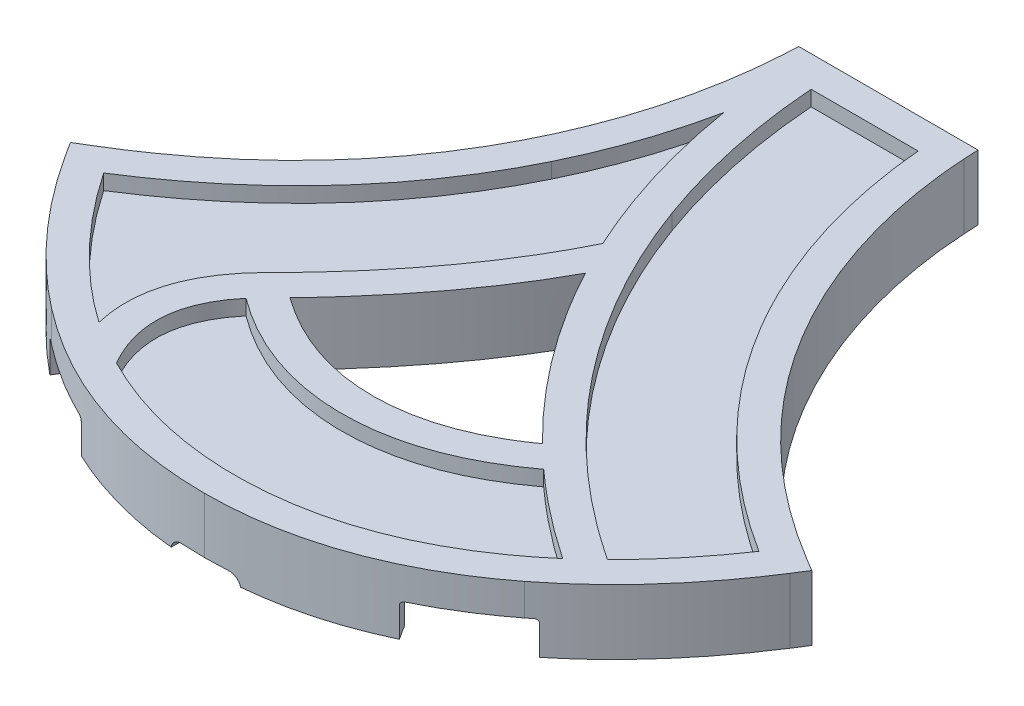
from build123d import *

# Parameters (mm, degrees)
BOSS_EXTRUDE1_DEPTH = 2.5
BOSS_EXTRUDE4_DEPTH = 4
BOSS_EXTRUDE6_DEPTH = 4
SKETCH23_R          = 1.675
CUT_EXTRUDE5_DEPTH  = 4.5
BOSS_EXTRUDE5_DEPTH = 2
BOSS_EXTRUDE7_DEPTH = 4
CUT_EXTRUDE1_DEPTH  = 15
CUT_EXTRUDE2_DEPTH  = 4
CUT_EXTRUDE3_DEPTH  = 15
CUT_EXTRUDE4_DEPTH  = 4
CUT_EXTRUDE6_DEPTH  = 0.3


with BuildPart() as part:
    # Sketch1 → Boss-Extrude1 (new body)
    with BuildSketch(Plane(origin=(0, 0, 0), x_dir=(1, 0, 0), z_dir=(0, 1, 0))):
        with BuildLine():
            Line((48.547041226, -13.77356451), (46.77347558, -12.705116653))
            add(Edge.make_bspline(
                [(46.77347558, -12.705116653), (17.003528636, 5.22980651), (12.429063845, 32.150778096), (11.844136588, 42.892659136)],
                knots=[0, 0, 0, 0, 1, 1, 1, 1], degree=3))
            Line((11.844136588, 42.892659136), (11.740234172, 44.800601737))
            Line((11.740234172, 44.800601737), (-11.731466174, 44.800601737))
            Line((-11.731466174, 44.800601737), (-11.83536859, 42.892659136))
            add(Edge.make_bspline(
                [(-11.83536859, 42.892659136), (-12.420033135, 32.1531425), (-16.994235215, 5.237425145), (-46.766415207, -12.700913268)],
                knots=[4, 4, 4, 4, 5, 5, 5, 5], degree=3))
            Line((-46.766415207, -12.700913268), (-48.539586785, -13.769361125))
            Line((-48.539586785, -13.769361125), (-47.425952543, -15.514291212))
            add(Edge.make_bspline(
                [(-47.425952543, -15.514291212), (-44.221791175, -20.535496986), (-38.763958811, -27.786861073), (-30.959324209, -33.817667318)],
                knots=[7, 7, 7, 7, 8, 8, 8, 8], degree=3))
            add(Edge.make_bspline(
                [(-30.959324209, -33.817667318), (-21.548865284, -41.089260193), (-11.131170292, -44.776416738), (0.004383999, -44.776416738)],
                knots=[8, 8, 8, 8, 9, 9, 9, 9], degree=3))
            add(Edge.make_bspline(
                [(0.004383999, -44.776416738), (11.137573886, -44.776416738), (21.55395532, -41.090311039), (30.963888823, -33.820557145)],
                knots=[9, 9, 9, 9, 10, 10, 10, 10], degree=3))
            add(Edge.make_bspline(
                [(30.963888823, -33.820557145), (38.769705626, -27.790276323), (44.228326125, -20.539437659), (47.433012916, -15.518757308)],
                knots=[10, 10, 10, 10, 11, 11, 11, 11], degree=3))
            Line((47.433012916, -15.518757308), (48.547041226, -13.77356451))
        make_face()
        with BuildLine():
            add(Edge.make_bspline(
                [(16.526280274, -17.02611406), (11.287253789, -20.800080352), (5.739508399, -22.717053662), (0.004383999, -22.717053662), (-5.746437416, -22.717053662), (-11.308763297, -20.789391276), (-16.560367097, -16.995032001)],
                knots=[0, 0, 0, 0, 1, 1, 1, 2, 2, 2, 2], degree=3))
            add(Edge.make_bspline(
                [(-16.560367097, -16.995032001), (-9.578627154, -9.767262695), (-4.026727637, -2.348009511), (0, 5.127529621)],
                knots=[2, 2, 2, 2, 3, 3, 3, 3], degree=3))
            add(Edge.make_bspline(
                [(0, 5.127529621), (3.742194614, -1.933779081), (9.0389848, -9.633214129), (16.526280274, -17.02611406)],
                knots=[3, 3, 3, 3, 4, 4, 4, 4], degree=3))
        make_face(mode=Mode.SUBTRACT)
    extrude(amount=BOSS_EXTRUDE1_DEPTH)

    # Sketch4 → Boss-Extrude4 (add)
    with BuildSketch(Plane.XZ):
        with BuildLine():
            Line((11.740234172, -44.800601737), (11.844136588, -42.892659136))
            add(Edge.make_bspline(
                [(46.77347558, 12.705116653), (17.003528636, -5.22980651), (12.429063845, -32.150778096), (11.844136588, -42.892659136)],
                knots=[0, 0, 0, 0, 1, 1, 1, 1], degree=3))
            Line((46.77347558, 12.705116653), (48.547041226, 13.77356451))
            Line((48.547041226, 13.77356451), (47.433012916, 15.518757308))
            add(Edge.make_bspline(
                [(30.963888822, 33.820557145), (38.769705626, 27.790276323), (44.228326125, 20.539437659), (47.433012916, 15.518757308)],
                knots=[10, 10, 10, 10, 11, 11, 11, 11], degree=3))
            add(Edge.make_bspline(
                [(0.004383999, 44.776416738), (11.137573886, 44.776416738), (21.55395532, 41.090311039), (30.963888823, 33.820557145)],
                knots=[9, 9, 9, 9, 10, 10, 10, 10], degree=3))
            add(Edge.make_bspline(
                [(-30.959324209, 33.817667318), (-21.548865284, 41.089260193), (-11.131170292, 44.776416738), (0.004383999, 44.776416738)],
                knots=[8, 8, 8, 8, 9, 9, 9, 9], degree=3))
            add(Edge.make_bspline(
                [(-47.425952543, 15.514291212), (-44.221791175, 20.535496986), (-38.763958811, 27.786861073), (-30.959324209, 33.817667318)],
                knots=[7, 7, 7, 7, 8, 8, 8, 8], degree=3))
            Line((-47.425952543, 15.514291212), (-48.539586785, 13.769361125))
            Line((-48.539586785, 13.769361125), (-46.766415207, 12.700913268))
            add(Edge.make_bspline(
                [(-11.83536859, -42.892659136), (-12.420033135, -32.1531425), (-16.994235215, -5.237425145), (-46.766415207, 12.700913268)],
                knots=[4, 4, 4, 4, 5, 5, 5, 5], degree=3))
            Line((-11.83536859, -42.892659136), (-11.731466174, -44.800601737))
            Line((-11.731466174, -44.800601737), (11.740234172, -44.800601737))
        make_face()
        with BuildLine():
            ThreePointArc((9.805103325, -40.070751264), (8.914967585, -41.838420571), (7.068404724, -42.550601737))
            Line((7.068404724, -42.550601737), (-7.059635396, -42.550601737))
            ThreePointArc((-7.059635396, -42.550601737), (-8.906188312, -41.838429583), (-9.79633136, -40.070777977))
            add(Edge.make_bspline(
                [(-9.79633136, -40.070777977), (-9.806604666, -39.966716592), (-9.885264947, -39.189368999), (-10.089133777, -37.474091774), (-10.520685288, -34.721752947), (-11.392209806, -30.437998952), (-13.039131532, -24.502854679), (-16.159080969, -16.744347379), (-20.674095646, -8.64514211), (-25.804589688, -1.864743805), (-30.84960564, 3.425181208), (-35.130098086, 7.285756623), (-39.088097424, 10.344941272), (-41.820471466, 12.223272957), (-42.846584297, 12.896477044), (-43.039031297, 13.021630577)],
                knots=[4.073001285, 4.073001285, 4.073001285, 4.073001285, 4.080745575, 4.130403431, 4.192357749, 4.254312068, 4.378220706, 4.502129344, 4.626037982, 4.74994662, 4.811900939, 4.873855258, 4.935809576, 4.964697167, 4.971310513, 4.971310513, 4.971310513, 4.971310513], degree=3))
            add(Edge.make_bspline(
                [(-43.039031297, 13.021630577), (-43.231478297, 13.14678411), (-44.006450367, 13.646377001), (-44.80581273, 14.143926159), (-45.400757791, 14.504556072)],
                knots=[4.971310513, 4.971310513, 4.971310513, 4.971310513, 4.977923858, 4.997763895, 4.997763895, 4.997763895, 4.997763895], degree=3))
            add(Edge.make_bspline(
                [(-45.400757791, 14.504556072), (-45.199334523, 14.817972831), (-44.805197618, 15.421588623), (-44.31229924, 16.152510125), (-43.971368584, 16.647306792), (-43.85393411, 16.816271088), (-43.794705215, 16.901116786)],
                knots=[7.013640908, 7.013640908, 7.013640908, 7.013640908, 7.075288337, 7.13550544, 7.150917297, 7.166329155, 7.166329155, 7.166329155, 7.166329155], degree=3))
            add(Edge.make_bspline(
                [(-43.794705215, 16.901116786), (-43.73547632, 16.985962483), (-43.371488665, 17.505125969), (-42.484759937, 18.737465955), (-41.011425283, 20.668321188), (-38.509551598, 23.700159309), (-35.600268698, 26.815686604), (-32.30259122, 29.847383546), (-30.497798956, 31.330829791), (-29.583579219, 32.037266879)],
                knots=[7.166329155, 7.166329155, 7.166329155, 7.166329155, 7.181741012, 7.260230625, 7.383525483, 7.506820342, 7.753410059, 7.876704917, 7.999999775, 7.999999775, 7.999999775, 7.999999775], degree=3))
            add(Edge.make_bspline(
                [(-29.583579219, 32.037266879), (-29.021484434, 32.471605303), (-27.875005392, 33.324670492), (-25.572281033, 34.90764148), (-22.640251162, 36.683922973), (-19.049635263, 38.484302425), (-14.164788894, 40.448254564), (-9.132084552, 41.758815894), (-3.965934864, 42.416362102), (-1.314502791, 42.526416738), (0.004383999, 42.526416738)],
                knots=[8.000000109, 8.000000109, 8.000000109, 8.000000109, 8.062500102, 8.125000095, 8.250000082, 8.375000068, 8.500000055, 8.750000027, 8.875000014, 9, 9, 9, 9], degree=3))
            add(Edge.make_bspline(
                [(0.004383999, 42.526416738), (1.322997387, 42.526416738), (3.973859488, 42.416394049), (9.139064598, 41.759033383), (14.170998845, 40.448831174), (19.055251222, 38.485399296), (22.645500719, 36.685488718), (25.577288185, 34.909662462), (27.879854434, 33.327093039), (29.026265905, 32.47424204), (29.588330417, 32.040012545)],
                knots=[9, 9, 9, 9, 9.125000061, 9.250000123, 9.500000245, 9.625000306, 9.750000368, 9.875000429, 9.93750046, 10.00000049, 10.00000049, 10.00000049, 10.00000049], degree=3))
            add(Edge.make_bspline(
                [(29.588330417, 32.040012545), (30.50268272, 31.333641732), (32.307756946, 29.850316117), (35.605921275, 26.818878382), (38.515636423, 23.703609409), (41.017883751, 20.672029865), (42.491328125, 18.741493214), (43.378103699, 17.509400822), (43.742061693, 16.99041662), (43.80130169, 16.905577471)],
                knots=[9.999999407, 9.999999407, 9.999999407, 9.999999407, 10.123293893, 10.246588378, 10.493177348, 10.616471833, 10.739766318, 10.818230456, 10.833642266, 10.833642266, 10.833642266, 10.833642266], degree=3))
            add(Edge.make_bspline(
                [(43.80130169, 16.905577471), (43.860541686, 16.820738321), (43.977998182, 16.651787163), (44.319086864, 16.156893212), (44.812166107, 15.425895465), (45.20644988, 14.822214052), (45.407907805, 14.508827514)],
                knots=[10.833642266, 10.833642266, 10.833642266, 10.833642266, 10.849054077, 10.864465888, 10.924708046, 10.986355288, 10.986355288, 10.986355288, 10.986355288], degree=3))
            add(Edge.make_bspline(
                [(45.407907805, 14.508827514), (44.812849726, 14.148169591), (44.013343118, 13.650577828), (43.23823363, 13.150932554), (43.045752709, 13.025765344)],
                knots=[0.002236341, 0.002236341, 0.002236341, 0.002236341, 0.022081342, 0.028696342, 0.028696342, 0.028696342, 0.028696342], degree=3))
            add(Edge.make_bspline(
                [(43.045752709, 13.025765344), (42.853271788, 12.900598135), (41.82742377, 12.227609173), (39.09541693, 10.349629878), (35.137863488, 7.290862821), (30.857614583, 3.430426247), (25.812878369, -1.859510107), (20.682655133, -8.640243605), (16.167852509, -16.740218222), (13.0480119, -24.499729565), (11.401107723, -30.435801971), (10.529564367, -34.720291025), (10.09795953, -37.473303909), (9.894057659, -39.189044935), (9.815377307, -39.966672637), (9.805103325, -40.070751264)],
                knots=[0.028696342, 0.028696342, 0.028696342, 0.028696342, 0.035311342, 0.064190776, 0.126145211, 0.188099646, 0.250054081, 0.373962951, 0.497871821, 0.621780691, 0.745689561, 0.807643996, 0.869598431, 0.919267543, 0.927011847, 0.927011847, 0.927011847, 0.927011847], degree=3))
        make_face(mode=Mode.SUBTRACT)
        with BuildLine():
            ThreePointArc((43.80130169, 16.905577471), (44.24586843, 14.80552987), (43.045752709, 13.025765344))
            add(Edge.make_bspline(
                [(45.407907805, 14.508827514), (44.812849726, 14.148169591), (44.013343118, 13.650577828), (43.23823363, 13.150932554), (43.045752709, 13.025765344)],
                knots=[0.002236341, 0.002236341, 0.002236341, 0.002236341, 0.022081342, 0.028696342, 0.028696342, 0.028696342, 0.028696342], degree=3))
            add(Edge.make_bspline(
                [(43.80130169, 16.905577471), (43.860541686, 16.820738321), (43.977998182, 16.651787163), (44.319086864, 16.156893212), (44.812166107, 15.425895465), (45.20644988, 14.822214052), (45.407907805, 14.508827514)],
                knots=[10.833642266, 10.833642266, 10.833642266, 10.833642266, 10.849054077, 10.864465888, 10.924708046, 10.986355288, 10.986355288, 10.986355288, 10.986355288], degree=3))
        make_face()
        with BuildLine():
            add(Edge.make_bspline(
                [(-43.039031297, 13.021630577), (-43.231478297, 13.14678411), (-44.006450367, 13.646377001), (-44.80581273, 14.143926159), (-45.400757791, 14.504556072)],
                knots=[4.971310513, 4.971310513, 4.971310513, 4.971310513, 4.977923858, 4.997763895, 4.997763895, 4.997763895, 4.997763895], degree=3))
            ThreePointArc((-43.039031297, 13.021630577), (-44.239051851, 14.801222913), (-43.794705215, 16.901116786))
            add(Edge.make_bspline(
                [(-45.400757791, 14.504556072), (-45.199334523, 14.817972831), (-44.805197618, 15.421588623), (-44.31229924, 16.152510125), (-43.971368584, 16.647306792), (-43.85393411, 16.816271088), (-43.794705215, 16.901116786)],
                knots=[7.013640908, 7.013640908, 7.013640908, 7.013640908, 7.075288337, 7.13550544, 7.150917297, 7.166329155, 7.166329155, 7.166329155, 7.166329155], degree=3))
        make_face()
        with BuildLine():
            add(Edge.make_bspline(
                [(18.561464236, 18.333050818), (18.468513073, 18.400008784), (18.204622743, 18.590075566), (17.563656149, 19.0512698), (16.574665128, 19.739291573), (14.974367301, 20.750082244), (12.932211839, 21.879677212), (9.603007896, 23.366039009), (5.327473808, 24.623488328), (0.045412031, 25.135736948), (-5.263804885, 24.635743019), (-9.549609453, 23.382446713), (-12.88923537, 21.896817249), (-14.937355843, 20.766749275), (-16.542499904, 19.754458694), (-17.548862094, 19.056086345), (-18.207846317, 18.580511083), (-18.486202434, 18.379423615), (-18.579376745, 18.312103835)],
                knots=[-0.045814481, -0.045814481, -0.045814481, -0.045814481, -0.028072413, 0.0044931, 0.075461372, 0.146429643, 0.288366187, 0.43030273, 0.714175817, 0.998048904, 1.281921991, 1.565795078, 1.707731622, 1.849668165, 1.920636437, 1.991604709, 2.026771683, 2.044513751, 2.044513751, 2.044513751, 2.044513751], degree=3))
            ThreePointArc((-18.579376745, 18.312103835), (-19.195034881, 17.228855671), (-18.779770658, 16.054114359))
            add(Edge.make_bspline(
                [(-18.779770658, 16.054114359), (-18.67958586, 15.950399151), (-18.479475319, 15.743149271), (-17.7934474, 15.031131805), (-16.162844302, 13.322118365), (-13.697949698, 10.57923691), (-10.892212401, 7.208486109), (-7.437816222, 2.692458315), (-4.798915439, -1.275880119), (-2.804827824, -4.685016446), (-2.080234341, -6.011416393), (-1.580006031, -6.938871271), (-1.393953417, -7.284205831), (-1.315217457, -7.430377562)],
                knots=[1.971300908, 1.971300908, 1.971300908, 1.971300908, 1.985650454, 2, 2.070329415, 2.226756105, 2.383182796, 2.539609486, 2.852462868, 2.930676213, 3.008889558, 3.03555208, 3.055105416, 3.055105416, 3.055105416, 3.055105416], degree=3))
            ThreePointArc((-1.315217457, -7.430377562), (0.010456844, -8.219022413), (1.330765757, -7.421427635))
            add(Edge.make_bspline(
                [(1.330765757, -7.421427635), (1.440317107, -7.214710459), (1.659442704, -6.801716289), (2.400482458, -5.413219547), (4.233261447, -2.06743675), (7.059369927, 2.349304029), (10.482267828, 6.942636294), (13.334966742, 10.396562794), (15.923476009, 13.233007565), (17.672245934, 14.992928174), (18.423225248, 15.737037399), (18.633384277, 15.94466706), (18.738631942, 16.048587822)],
                knots=[2.941450747, 2.941450747, 2.941450747, 2.941450747, 2.970725373, 3, 3.139349431, 3.45434662, 3.611845215, 3.76934381, 3.926842405, 4, 4.014056833, 4.028113667, 4.028113667, 4.028113667, 4.028113667], degree=3))
            ThreePointArc((18.738631942, 16.048587822), (19.180230847, 17.231936757), (18.561464236, 18.333050818))
        make_face()
        with BuildLine():
            add(Edge.make_bspline(
                [(0, -5.127529621), (3.742194614, 1.933779081), (9.0389848, 9.633214129), (16.526280274, 17.02611406)],
                knots=[3, 3, 3, 3, 4, 4, 4, 4], degree=3))
            add(Edge.make_bspline(
                [(-16.560367097, 16.995032001), (-9.578627154, 9.767262695), (-4.026727637, 2.348009511), (0, -5.127529621)],
                knots=[2, 2, 2, 2, 3, 3, 3, 3], degree=3))
            add(Edge.make_bspline(
                [(16.526280274, 17.02611406), (11.287253789, 20.800080352), (5.739508399, 22.717053662), (0.004383999, 22.717053662), (-5.746437416, 22.717053662), (-11.308763297, 20.789391276), (-16.560367097, 16.995032001)],
                knots=[0, 0, 0, 0, 1, 1, 1, 2, 2, 2, 2], degree=3))
        make_face(mode=Mode.SUBTRACT)
    extrude(amount=BOSS_EXTRUDE4_DEPTH)

    # Sketch15 → Boss-Extrude6 (add)
    with BuildSketch(Plane.XZ):
        with BuildLine():
            ThreePointArc((39.578382594, 17.917442115), (38.335373201, 15.831869177), (38.884461201, 13.466876745))
            ThreePointArc((38.884461201, 13.466876745), (39.348093126, 11.459484685), (38.28721892, 9.693380679))
            add(Edge.make_bspline(
                [(43.045752709, 13.025765344), (42.853271788, 12.900598135), (41.82742377, 12.227609173), (40.221396527, 11.123627344), (38.861117202, 10.125976897), (38.28721892, 9.693380679)],
                knots=[0.028696342, 0.028696342, 0.028696342, 0.028696342, 0.035311342, 0.064190776, 0.085982267, 0.085982267, 0.085982267, 0.085982267], degree=3))
            ThreePointArc((43.045752709, 13.025765344), (44.24586843, 14.80552987), (43.80130169, 16.905577471))
            add(Edge.make_bspline(
                [(40.030465817, 21.860461098), (40.357622354, 21.465654803), (41.285233935, 20.321742242), (42.491328125, 18.741493214), (43.378103699, 17.509400822), (43.742061693, 16.99041662), (43.80130169, 16.905577471)],
                knots=[10.552156845, 10.552156845, 10.552156845, 10.552156845, 10.616471833, 10.739766318, 10.818230456, 10.833642266, 10.833642266, 10.833642266, 10.833642266], degree=3))
            ThreePointArc((40.030465817, 21.860461098), (40.645090189, 19.79256582), (39.578382594, 17.917442115))
        make_face()
        with BuildLine():
            ThreePointArc((-39.571908118, 17.913503053), (-38.328607865, 15.827859379), (-38.877699691, 13.462652577))
            ThreePointArc((-38.877699691, 13.462652577), (-39.341361409, 11.455249041), (-38.280488276, 9.689123526))
            add(Edge.make_bspline(
                [(-38.280488276, 9.689123526), (-38.854148563, 10.121542429), (-40.214453624, 11.119238827), (-41.820471466, 12.223272957), (-42.846584297, 12.896477044), (-43.039031297, 13.021630577)],
                knots=[4.914028868, 4.914028868, 4.914028868, 4.914028868, 4.935809576, 4.964697167, 4.971310513, 4.971310513, 4.971310513, 4.971310513], degree=3))
            ThreePointArc((-43.039031297, 13.021630577), (-44.239051851, 14.801222913), (-43.794705215, 16.901116786))
            add(Edge.make_bspline(
                [(-43.794705215, 16.901116786), (-43.73547632, 16.985962483), (-43.371488665, 17.505125969), (-42.484759937, 18.737465955), (-41.278829762, 20.317878513), (-40.351469454, 21.461758125), (-40.024474361, 21.856467741)],
                knots=[7.166329155, 7.166329155, 7.166329155, 7.166329155, 7.181741012, 7.260230625, 7.383525483, 7.447819714, 7.447819714, 7.447819714, 7.447819714], degree=3))
            ThreePointArc((-40.024474361, 21.856467741), (-40.638845986, 19.78849659), (-39.571908118, 17.913503053))
        make_face()
        with BuildLine():
            ThreePointArc((-2.74431224, -9.677873395), (0.010339959, -13.877525526), (2.751099323, -9.668793547))
            ThreePointArc((2.751099323, -9.668793547), (2.249212243, -6.9682611), (3.003386077, -4.327051535))
            add(Edge.make_bspline(
                [(1.330765757, -7.421427635), (1.440317107, -7.214710459), (1.659442704, -6.801716289), (2.211537719, -5.767247996), (2.657752033, -4.946292282), (3.003386077, -4.327051535)],
                knots=[2.941450747, 2.941450747, 2.941450747, 2.941450747, 2.970725373, 3, 3.088890714, 3.088890714, 3.088890714, 3.088890714], degree=3))
            ThreePointArc((1.330765757, -7.421427635), (0.010456844, -8.219022413), (-1.315217457, -7.430377562))
            add(Edge.make_bspline(
                [(-3.040899779, -4.290110226), (-2.965420364, -4.421517631), (-2.566938835, -5.120482607), (-2.080234341, -6.011416393), (-1.580006031, -6.938871271), (-1.393953417, -7.284205831), (-1.315217457, -7.430377562)],
                knots=[2.912572306, 2.912572306, 2.912572306, 2.912572306, 2.930676213, 3.008889558, 3.03555208, 3.055105416, 3.055105416, 3.055105416, 3.055105416], degree=3))
            ThreePointArc((-3.040899779, -4.290110226), (-2.25277345, -6.948770076), (-2.74431224, -9.677873395))
        make_face()
    extrude(amount=BOSS_EXTRUDE6_DEPTH)

    # Sketch23 → Cut-Extrude5 (cut)
    with BuildSketch(Plane.XZ.offset(4)):
        with Locations((-41.539782977, 15.327005703)):
            Circle(SKETCH23_R)
        with Locations((0.005383187, -10.877529621)):
            Circle(SKETCH23_R)
        with Locations((41.546574957, 15.331186362)):
            Circle(SKETCH23_R)
    extrude(amount=-CUT_EXTRUDE5_DEPTH, mode=Mode.SUBTRACT)

    # Sketch12 → Boss-Extrude5 (add)
    with BuildSketch(Plane(origin=(0, 2.5, 0), x_dir=(1, 0, 0), z_dir=(0, 1, 0))):
        with BuildLine():
            Line((-46.766415207, -12.700913268), (-48.539586785, -13.769361125))
            Line((-48.539586785, -13.769361125), (-47.425952543, -15.514291212))
            add(Edge.make_bspline(
                [(-47.425952543, -15.514291212), (-44.221791175, -20.535496986), (-38.763958811, -27.786861073), (-30.959324209, -33.817667318)],
                knots=[7, 7, 7, 7, 8, 8, 8, 8], degree=3))
            add(Edge.make_bspline(
                [(-30.959324209, -33.817667318), (-21.548865284, -41.089260193), (-11.131170292, -44.776416738), (0.004383999, -44.776416738)],
                knots=[8, 8, 8, 8, 9, 9, 9, 9], degree=3))
            add(Edge.make_bspline(
                [(0.004383999, -44.776416738), (11.137573886, -44.776416738), (21.55395532, -41.090311039), (30.963888823, -33.820557145)],
                knots=[9, 9, 9, 9, 10, 10, 10, 10], degree=3))
            add(Edge.make_bspline(
                [(30.963888823, -33.820557145), (38.769705626, -27.790276323), (44.228326125, -20.539437659), (47.433012916, -15.518757308)],
                knots=[10, 10, 10, 10, 11, 11, 11, 11], degree=3))
            Line((47.433012916, -15.518757308), (48.547041226, -13.77356451))
            Line((48.547041226, -13.77356451), (46.77347558, -12.705116653))
            add(Edge.make_bspline(
                [(46.77347558, -12.705116653), (17.003528636, 5.22980651), (12.429063845, 32.150778096), (11.844136588, 42.892659136)],
                knots=[0, 0, 0, 0, 1, 1, 1, 1], degree=3))
            Line((11.844136588, 42.892659136), (11.740234172, 44.800601737))
            Line((11.740234172, 44.800601737), (-11.731466174, 44.800601737))
            Line((-11.731466174, 44.800601737), (-11.83536859, 42.892659136))
            add(Edge.make_bspline(
                [(-11.83536859, 42.892659136), (-12.420033135, 32.1531425), (-16.994235215, 5.237425145), (-46.766415207, -12.700913268)],
                knots=[4, 4, 4, 4, 5, 5, 5, 5], degree=3))
        make_face()
        with BuildLine():
            Line((-6.075253754, 40.765352394), (7.946679451, 40.765352394))
            add(Edge.make_bspline(
                [(7.946679451, 40.765352394), (8.483530495, 34.33798307), (10.170926753, 25.254994087), (14.899209154, 15.549116028)],
                knots=[3, 3, 3, 3, 4, 4, 4, 4], degree=3))
            add(Edge.make_bspline(
                [(14.899209154, 15.549116028), (20.914646773, 3.201016598), (30.331936199, -7.088081093), (42.906887049, -15.058749392)],
                knots=[4, 4, 4, 4, 5, 5, 5, 5], degree=3))
            add(Edge.make_bspline(
                [(42.906887049, -15.058749392), (40.659012127, -18.38065479), (37.675610555, -22.224732226), (33.936157993, -25.911002119)],
                knots=[5, 5, 5, 5, 6, 6, 6, 6], degree=3))
            add(Edge.make_bspline(
                [(33.936157993, -25.911002119), (13.025632507, -12.135114696), (3.309968443, 5.324399086), (-1.165733226, 17.6611855)],
                knots=[0, 0, 0, 0, 1, 1, 1, 1], degree=3))
            add(Edge.make_bspline(
                [(-1.165733226, 17.6611855), (-4.454734004, 26.727032556), (-5.669774903, 34.935701095), (-6.075253754, 40.765352394)],
                knots=[1, 1, 1, 1, 2, 2, 2, 2], degree=3))
        make_face(mode=Mode.SUBTRACT)
        with BuildLine():
            add(Edge.make_bspline(
                [(-26.267115388, -32.302790447), (-33.773473868, -27.088343912), (-39.285999492, -20.396292706), (-42.899826676, -15.054546007)],
                knots=[6, 6, 6, 6, 7, 7, 7, 7], degree=3))
            add(Edge.make_bspline(
                [(-42.899826676, -15.054546007), (-30.326189384, -7.083877708), (-20.909031314, 3.204694559), (-14.892674204, 15.55121772)],
                knots=[0, 0, 0, 0, 1, 1, 1, 1], degree=3))
            add(Edge.make_bspline(
                [(-14.892674204, 15.55121772), (-11.960583481, 21.568297287), (-10.198248754, 27.344092718), (-9.153674809, 32.396791039)],
                knots=[1, 1, 1, 1, 2, 2, 2, 2], degree=3))
            add(Edge.make_bspline(
                [(-9.153674809, 32.396791039), (-8.369595781, 27.60879102), (-7.074263666, 22.115509017), (-4.959025235, 16.285102424)],
                knots=[2, 2, 2, 2, 3, 3, 3, 3], degree=3))
            add(Edge.make_bspline(
                [(-4.959025235, 16.285102424), (-4.200724778, 14.194854429), (-3.298458394, 11.963957241), (-2.227202807, 9.632343014)],
                knots=[3, 3, 3, 3, 4, 4, 4, 4], degree=3))
            add(Edge.make_bspline(
                [(-2.227202807, 9.632343014), (-6.405876235, 1.067437618), (-12.722414125, -7.478995873), (-21.02725151, -15.783833258)],
                knots=[4, 4, 4, 4, 5, 5, 5, 5], degree=3))
            add(Edge.make_bspline(
                [(-21.02725151, -15.783833258), (-25.949956874, -20.706637139), (-27.720025172, -26.418068241), (-26.267115388, -32.302790447)],
                knots=[5, 5, 5, 5, 6, 6, 6, 6], degree=3))
        make_face(mode=Mode.SUBTRACT)
        with BuildLine():
            add(Edge.make_bspline(
                [(0, 5.127529621), (3.742194614, -1.933779081), (9.0389848, -9.633214129), (16.526280274, -17.02611406)],
                knots=[3, 3, 3, 3, 4, 4, 4, 4], degree=3))
            add(Edge.make_bspline(
                [(16.526280274, -17.02611406), (11.287253789, -20.800080352), (5.739508399, -22.717053662), (0.004383999, -22.717053662), (-5.746437416, -22.717053662), (-11.308763297, -20.789391276), (-16.560367097, -16.995032001)],
                knots=[0, 0, 0, 0, 1, 1, 1, 2, 2, 2, 2], degree=3))
            add(Edge.make_bspline(
                [(-16.560367097, -16.995032001), (-9.578627154, -9.767262695), (-4.026727637, -2.348009511), (0, 5.127529621)],
                knots=[2, 2, 2, 2, 3, 3, 3, 3], degree=3))
        make_face(mode=Mode.SUBTRACT)
        with BuildLine():
            add(Edge.make_bspline(
                [(30.883367734, -28.727680377), (23.245834094, -35.30482812), (13.001692917, -40.741167395), (0.004383999, -40.741167395), (-7.81619391, -40.741167395), (-14.63953521, -38.772571266), (-20.498446007, -35.771962087)],
                knots=[4, 4, 4, 4, 5, 5, 5, 6, 6, 6, 6], degree=3))
            add(Edge.make_bspline(
                [(-20.498446007, -35.771962087), (-23.817675032, -30.084372057), (-23.437170197, -24.768633801), (-19.371955318, -19.942655544)],
                knots=[0, 0, 0, 0, 1, 1, 1, 1], degree=3))
            add(Edge.make_bspline(
                [(-19.371955318, -19.942655544), (-13.294452096, -24.461491165), (-6.784788381, -26.752303006), (0.004383999, -26.752303006), (6.841550495, -26.752303006), (13.395563202, -24.429358259), (19.510043074, -19.846486699)],
                knots=[1, 1, 1, 1, 2, 2, 2, 3, 3, 3, 3], degree=3))
            add(Edge.make_bspline(
                [(19.510043074, -19.846486699), (22.88705222, -22.905270066), (26.661790227, -25.888967188), (30.883367734, -28.727680377)],
                knots=[3, 3, 3, 3, 4, 4, 4, 4], degree=3))
        make_face(mode=Mode.SUBTRACT)
    extrude(amount=BOSS_EXTRUDE5_DEPTH)

    # Sketch20 → Boss-Extrude7 (add)
    with BuildSketch(Plane.XZ):
        with BuildLine():
            Line((-38.280488276, 9.689123526), (-18.779770658, 16.054114359))
            ThreePointArc((-18.779770658, 16.054114359), (-19.195034881, 17.228855671), (-18.579376745, 18.312103835))
            Line((-18.579376745, 18.312103835), (-40.024474361, 21.856467741))
            ThreePointArc((-40.024474361, 21.856467741), (-40.638845986, 19.78849659), (-39.571908118, 17.913503053))
            ThreePointArc((-39.571908118, 17.913503053), (-38.328607865, 15.827859379), (-38.877699691, 13.462652577))
            ThreePointArc((-38.877699691, 13.462652577), (-39.341361409, 11.455249041), (-38.280488276, 9.689123526))
        make_face()
        with BuildLine():
            Line((38.28721892, 9.693380679), (18.738631942, 16.048587822))
            ThreePointArc((18.738631942, 16.048587822), (19.180230847, 17.231936757), (18.561464236, 18.333050818))
            Line((18.561464236, 18.333050818), (40.030465817, 21.860461098))
            ThreePointArc((40.030465817, 21.860461098), (40.645090189, 19.79256582), (39.578382594, 17.917442115))
            ThreePointArc((39.578382594, 17.917442115), (38.335373201, 15.831869177), (38.884461201, 13.466876745))
            ThreePointArc((38.884461201, 13.466876745), (39.348093126, 11.459484685), (38.28721892, 9.693380679))
        make_face()
    extrude(amount=BOSS_EXTRUDE7_DEPTH)

    # Sketch16 → Cut-Extrude1 (cut)
    with BuildSketch(Plane(origin=(-26.623119691, -4, 36.869577592), x_dir=(0.843372114, 0, 0.537329953), z_dir=(-0.537329953, 0, 0.843372114))):
        with BuildLine():
            Line((-6.141888368, -1.85), (6.158111632, -1.85))
            ThreePointArc((6.158111632, -1.85), (6.511665022, -1.703553391), (6.658111632, -1.35))
            Line((6.658111632, -1.35), (6.658111632, 3.85))
            ThreePointArc((6.658111632, 3.85), (6.511665022, 4.203553391), (6.158111632, 4.35))
            Line((6.158111632, 4.35), (-6.141888368, 4.35))
            ThreePointArc((-6.141888368, 4.35), (-6.495441759, 4.203553391), (-6.641888368, 3.85))
            Line((-6.641888368, 3.85), (-6.641888368, -1.35))
            ThreePointArc((-6.641888368, -1.35), (-6.495441759, -1.703553391), (-6.141888368, -1.85))
        make_face()
    extrude(amount=-CUT_EXTRUDE1_DEPTH, mode=Mode.SUBTRACT)

    # Sketch17 → Cut-Extrude2 (cut)
    with BuildSketch(Plane(origin=(0.004383999, -4, 44.776416738), x_dir=(1, 0, 0), z_dir=(0, 0, 1))):
        with BuildLine():
            Line((-3.077374703, -2.644999296), (3.062625297, -2.644999296))
            ThreePointArc((3.062625297, -2.644999296), (4.123285469, -2.205659468), (4.562625297, -1.144999296))
            Line((4.562625297, -1.144999296), (4.562625297, -0.294999296))
            ThreePointArc((4.562625297, -0.294999296), (4.123285469, 0.765660875), (3.062625297, 1.205000704))
            Line((3.062625297, 1.205000704), (-3.077374703, 1.205000704))
            ThreePointArc((-3.077374703, 1.205000704), (-4.138034874, 0.765660875), (-4.577374703, -0.294999296))
            Line((-4.577374703, -0.294999296), (-4.577374703, -1.144999296))
            ThreePointArc((-4.577374703, -1.144999296), (-4.138034874, -2.205659468), (-3.077374703, -2.644999296))
        make_face()
    extrude(amount=-CUT_EXTRUDE2_DEPTH, mode=Mode.SUBTRACT)

    # Sketch18 → Cut-Extrude3 (cut)
    with BuildSketch(Plane(origin=(26.631782756, -4, 36.869264143), x_dir=(0.843372249, 0, -0.53732974), z_dir=(0.53732974, 0, 0.843372249))):
        with BuildLine():
            Line((6.191428119, 4.35), (-6.108569064, 4.35))
            add(Edge.make_bspline(
                [(-6.108569064, 4.35), (-6.608568949, 4.35), (-6.608568949, 3.85)],
                knots=[0, 0, 0, 1.570796327, 1.570796327, 1.570796327], degree=2, weights=[1, 0.707106781, 1]))
            Line((-6.608568949, 3.85), (-6.608568949, -1.35))
            add(Edge.make_bspline(
                [(-6.608568949, -1.35), (-6.608568949, -1.85), (-6.108569064, -1.85)],
                knots=[4.71238898, 4.71238898, 4.71238898, 6.283185307, 6.283185307, 6.283185307], degree=2, weights=[1, 0.707106781, 1]))
            Line((-6.108569064, -1.85), (6.191428119, -1.85))
            add(Edge.make_bspline(
                [(6.191428119, -1.85), (6.691428005, -1.85), (6.691428005, -1.35)],
                knots=[0, 0, 0, 1.570796327, 1.570796327, 1.570796327], degree=2, weights=[1, 0.707106781, 1]))
            Line((6.691428005, -1.35), (6.691428005, 3.85))
            add(Edge.make_bspline(
                [(6.691428005, 3.85), (6.691428005, 4.35), (6.191428119, 4.35)],
                knots=[4.71238898, 4.71238898, 4.71238898, 6.283185307, 6.283185307, 6.283185307], degree=2, weights=[1, 0.707106781, 1]))
        make_face()
    extrude(amount=-CUT_EXTRUDE3_DEPTH, mode=Mode.SUBTRACT)

    # Sketch19 → Cut-Extrude4 (cut)
    with BuildSketch(Plane(origin=(0, 0, -44.800601737), x_dir=(-1, 0, 0), z_dir=(0, 0, -1))):
        with BuildLine():
            Line((3.072989688, -2.794999688), (-3.067010312, -2.794999688))
            ThreePointArc((-3.067010312, -2.794999688), (-4.127670484, -3.234339516), (-4.567010312, -4.294999688))
            Line((-4.567010312, -4.294999688), (-4.567010312, -5.144999688))
            ThreePointArc((-4.567010312, -5.144999688), (-4.127670484, -6.20565986), (-3.067010312, -6.644999688))
            Line((-3.067010312, -6.644999688), (3.072989688, -6.644999688))
            ThreePointArc((3.072989688, -6.644999688), (4.13364986, -6.20565986), (4.572989688, -5.144999688))
            Line((4.572989688, -5.144999688), (4.572989688, -4.294999688))
            ThreePointArc((4.572989688, -4.294999688), (4.13364986, -3.234339516), (3.072989688, -2.794999688))
        make_face()
    extrude(amount=-CUT_EXTRUDE4_DEPTH, mode=Mode.SUBTRACT)

    # Sketch24 → Cut-Extrude6 (cut)
    with BuildSketch(Plane.XZ.offset(4)):
        with BuildLine():
            Line((18.738631942, 16.048587822), (38.28721892, 9.693380679))
            ThreePointArc((38.28721892, 9.693380679), (39.348093126, 11.459484685), (38.884461201, 13.466876745))
            ThreePointArc((38.884461201, 13.466876745), (38.335373201, 15.831869177), (39.578382594, 17.917442115))
            ThreePointArc((39.578382594, 17.917442115), (40.645090189, 19.79256582), (40.030465817, 21.860461098))
            Line((40.030465817, 21.860461098), (18.561464236, 18.333050818))
            add(Edge.make_bspline(
                [(18.561464236, 18.333050818), (18.468513073, 18.400008784), (18.204622743, 18.590075566), (17.563656149, 19.0512698), (16.574665128, 19.739291573), (14.974367301, 20.750082244), (12.932211839, 21.879677212), (9.603007896, 23.366039009), (5.327473808, 24.623488328), (0.045412031, 25.135736948), (-5.263804885, 24.635743019), (-9.549609453, 23.382446713), (-12.88923537, 21.896817249), (-14.937355843, 20.766749275), (-16.542499904, 19.754458694), (-17.548862094, 19.056086345), (-18.207846317, 18.580511083), (-18.486202434, 18.379423615), (-18.579376745, 18.312103835)],
                knots=[-0.045814481, -0.045814481, -0.045814481, -0.045814481, -0.028072413, 0.0044931, 0.075461372, 0.146429643, 0.288366187, 0.43030273, 0.714175817, 0.998048904, 1.281921991, 1.565795078, 1.707731622, 1.849668165, 1.920636437, 1.991604709, 2.026771683, 2.044513751, 2.044513751, 2.044513751, 2.044513751], degree=3))
            Line((-18.579376745, 18.312103835), (-40.024474361, 21.856467741))
            ThreePointArc((-40.024474361, 21.856467741), (-40.638845986, 19.78849659), (-39.571908118, 17.913503053))
            ThreePointArc((-39.571908118, 17.913503053), (-38.328607865, 15.827859379), (-38.877699691, 13.462652577))
            ThreePointArc((-38.877699691, 13.462652577), (-39.341361409, 11.455249041), (-38.280488276, 9.689123526))
            Line((-38.280488276, 9.689123526), (-18.779770658, 16.054114359))
            add(Edge.make_bspline(
                [(-18.779770658, 16.054114359), (-18.67958586, 15.950399151), (-18.479475319, 15.743149271), (-17.7934474, 15.031131805), (-16.162844302, 13.322118365), (-13.697949698, 10.57923691), (-10.892212401, 7.208486109), (-7.437816222, 2.692458315), (-4.88617569, -1.144659494), (-3.291510071, -3.853805203), (-3.040899779, -4.290110226)],
                knots=[1.971300908, 1.971300908, 1.971300908, 1.971300908, 1.985650454, 2, 2.070329415, 2.226756105, 2.383182796, 2.539609486, 2.852462868, 2.912572306, 2.912572306, 2.912572306, 2.912572306], degree=3))
            ThreePointArc((-3.040899779, -4.290110226), (-2.25277345, -6.948770076), (-2.74431224, -9.677873395))
            ThreePointArc((-2.74431224, -9.677873395), (0.010339959, -13.877525526), (2.751099323, -9.668793547))
            ThreePointArc((2.751099323, -9.668793547), (2.249212243, -6.9682611), (3.003386077, -4.327051535))
            add(Edge.make_bspline(
                [(3.003386077, -4.327051535), (3.199584866, -3.975540199), (4.64384699, -1.425759362), (7.059369927, 2.349304029), (10.482267828, 6.942636294), (13.334966742, 10.396562794), (15.923476009, 13.233007565), (17.672245934, 14.992928174), (18.423225248, 15.737037399), (18.633384277, 15.94466706), (18.738631942, 16.048587822)],
                knots=[3.088890714, 3.088890714, 3.088890714, 3.088890714, 3.139349431, 3.45434662, 3.611845215, 3.76934381, 3.926842405, 4, 4.014056833, 4.028113667, 4.028113667, 4.028113667, 4.028113667], degree=3))
        make_face()
    extrude(amount=-CUT_EXTRUDE6_DEPTH, mode=Mode.SUBTRACT)


solid = part.part
